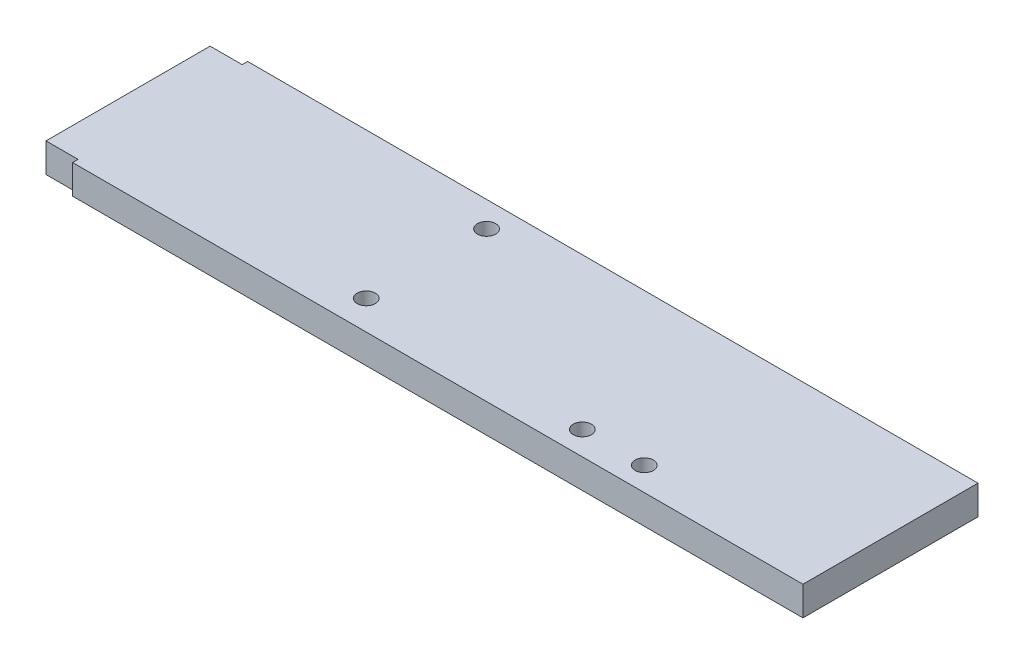
from build123d import *

# Parameters (mm, degrees)
BOSS_EXTRUDE3_DEPTH     = 1.6
SKETCH2_R               = 0.5
CUT_EXTRUDE1_DEPTH      = 1
CUT_EXTRUDE1_DEPTH_BACK = 2.6


with BuildPart() as part:
    # Sketch1 → Boss-Extrude3 (new body)
    with BuildSketch(Plane(origin=(0, 0, 0), x_dir=(1, 0, 0), z_dir=(0, 1, 0))):
        Polygon((21.251265924, -1.81006359), (21.251265924, -11.41006359), (-18.799734076, -11.41006359), (-18.799734076, -11.11006359), (-20.559734076, -11.11006359), (-20.559734076, -2.11006359), (-18.799734076, -2.11006359), (-18.799734076, -1.81006359), align=None)
    extrude(amount=BOSS_EXTRUDE3_DEPTH)

    # Sketch2 → Cut-Extrude1 (cut, two sides)
    with BuildSketch(Plane(origin=(0, 1.6, 0), x_dir=(1, 0, 0), z_dir=(0, 1, 0))) as cut_extrude1_sk:
        with Locations((-4.299734334, -3.210062239)):
            Circle(SKETCH2_R)
        with Locations((-4.299734334, -9.810062239)):
            Circle(SKETCH2_R)
        with Locations((7.851265666, -10.110062239)):
            Circle(SKETCH2_R)
        with Locations((11.251265666, -10.110062239)):
            Circle(SKETCH2_R)
    extrude(amount=CUT_EXTRUDE1_DEPTH, mode=Mode.SUBTRACT)
    extrude(cut_extrude1_sk.sketch, amount=-CUT_EXTRUDE1_DEPTH_BACK, mode=Mode.SUBTRACT)


solid = part.part
